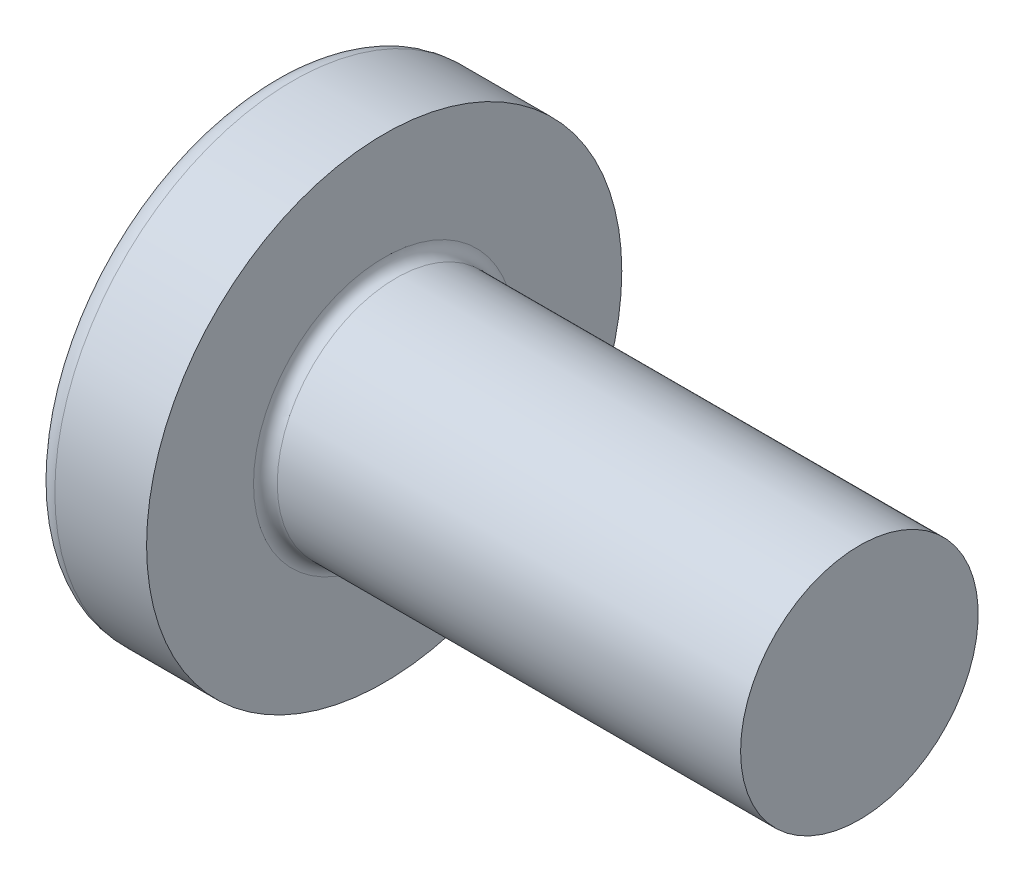
from build123d import *

# Parameters (mm, degrees)
FILLET1_R    = 0.2
SKETCH3_W    = 1.03
SKETCH3_H    = 4.3
SKETCH4_W    = 1.03
SKETCH4_H    = 1.966638154
RECPAT_COUNT = 2
RECPAT_ANGLE = 90


with BuildPart() as part:
    # BodySke → Base-Revolve (revolve)
    with BuildSketch(Plane.XY, mode=Mode.PRIVATE) as base_revolve_sk:
        with BuildLine():
            Line((3.1, 2), (3.1, 4))
            Line((3.1, 4), (1.555305874, 4))
            ThreePointArc((1.555305874, 4), (1.392873227, 3.961271902), (1.265388955, 3.853420195))
            ThreePointArc((1.265388955, 3.853420195), (0.324444487, 2.027933456), (0, 0))
            Line((0, 0), (11.1, 0))
            Line((11.1, 0), (11.1, 2))
            Line((11.1, 2), (3.1, 2))
        make_face()
    revolve(base_revolve_sk.sketch.rotate(Axis((-25.4, 0, 0), (1, 0, 0)), 90), axis=Axis((-25.4, 0, 0), (1, 0, 0)))  # turned: the seam where the file's is

    # Fillet1
    fillet1_edges = [part.edges().sort_by_distance(p)[0] for p in [
        (3.1, 0, -2),
    ]]
    fillet(fillet1_edges, radius=FILLET1_R)

    # Sketch3 → Recess section 0
    with BuildSketch(Plane(origin=(0, 0, 0), x_dir=(0, 0, -1), z_dir=(1, 0, 0))):
        Rectangle(SKETCH3_W, SKETCH3_H)
    # Sketch4 → Recess section 1
    with BuildSketch(Plane(origin=(2.34, 0, 0), x_dir=(0, 0, -1), z_dir=(1, 0, 0))):
        Rectangle(SKETCH4_W, SKETCH4_H)
    recess = loft(mode=Mode.SUBTRACT)

    # RecPat: Recess ×2 about axis
    recpat_axis = Axis((-25.4, 0, 0), (1, 0, 0))
    for i in range(1, RECPAT_COUNT):
        add(recess.rotate(recpat_axis, i * RECPAT_ANGLE / (RECPAT_COUNT - 1)), mode=Mode.SUBTRACT)

    # RecCorSke → RecessCore (revolve, cut)
    with BuildSketch(Plane.XY, mode=Mode.PRIVATE) as recesscore_sk:
        Polygon((0, 0), (0, 1.01462874), (2.34, 0.851), (2.616506661, 0), align=None)
    revolve(recesscore_sk.sketch.rotate(Axis((-3.175, 0, 0), (1, 0, 0)), 90), axis=Axis((-3.175, 0, 0), (1, 0, 0)), mode=Mode.SUBTRACT)  # turned: the seam where the file's is


solid = part.part
